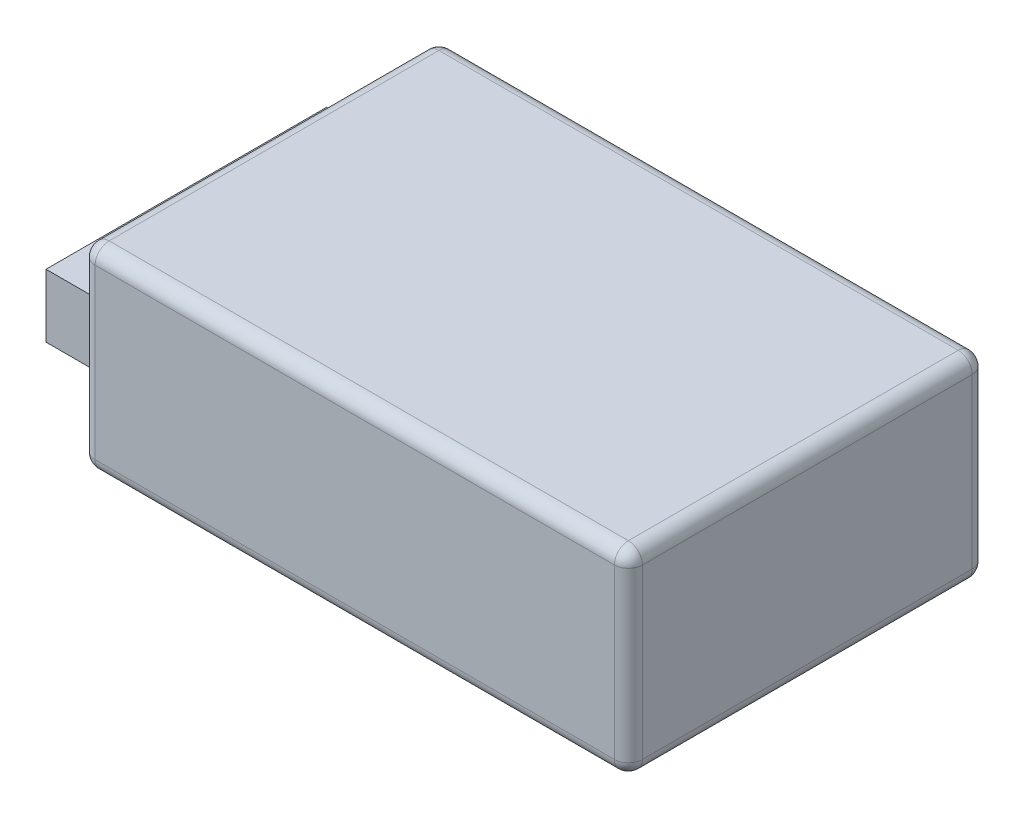
from build123d import *

# Parameters (mm, degrees)
SKETCH2_W           = 78
SKETCH2_H           = 51
BOSS_EXTRUDE1_DEPTH = 28
SKETCH3_W           = 40
SKETCH3_H           = 9
BOSS_EXTRUDE2_DEPTH = 14
FILLET1_R           = 2


with BuildPart() as part:
    # Sketch2 → Boss-Extrude1 (new body)
    with BuildSketch(Plane(origin=(0, 0, 0), x_dir=(1, 0, 0), z_dir=(0, 1, 0))):
        Rectangle(SKETCH2_W, SKETCH2_H)
    extrude(amount=BOSS_EXTRUDE1_DEPTH)

    # Fillet1
    fillet1_edges = [part.edges().sort_by_distance(p)[0] for p in [
        (-39, 28, 0),
        (0, 28, 25.5),
        (39, 28, 0),
        (0, 0, 25.5),
        (-39, 0, 0),
        (0, 0, -25.5),
        (39, 0, 0),
        (39, 14, 25.5),
        (-39, 14, 25.5),
        (-39, 14, -25.5),
        (39, 14, -25.5),
        (0, 28, -25.5),
    ]]
    fillet(fillet1_edges, radius=FILLET1_R)


with BuildPart() as body_2:
    # Sketch3 → Boss-Extrude2 (new body)
    with BuildSketch(Plane.ZY.offset(39)):
        with Locations((-3.5, 8.5)):
            Rectangle(SKETCH3_W, SKETCH3_H)
    extrude(amount=BOSS_EXTRUDE2_DEPTH)


solid = Compound([part.part, body_2.part])
